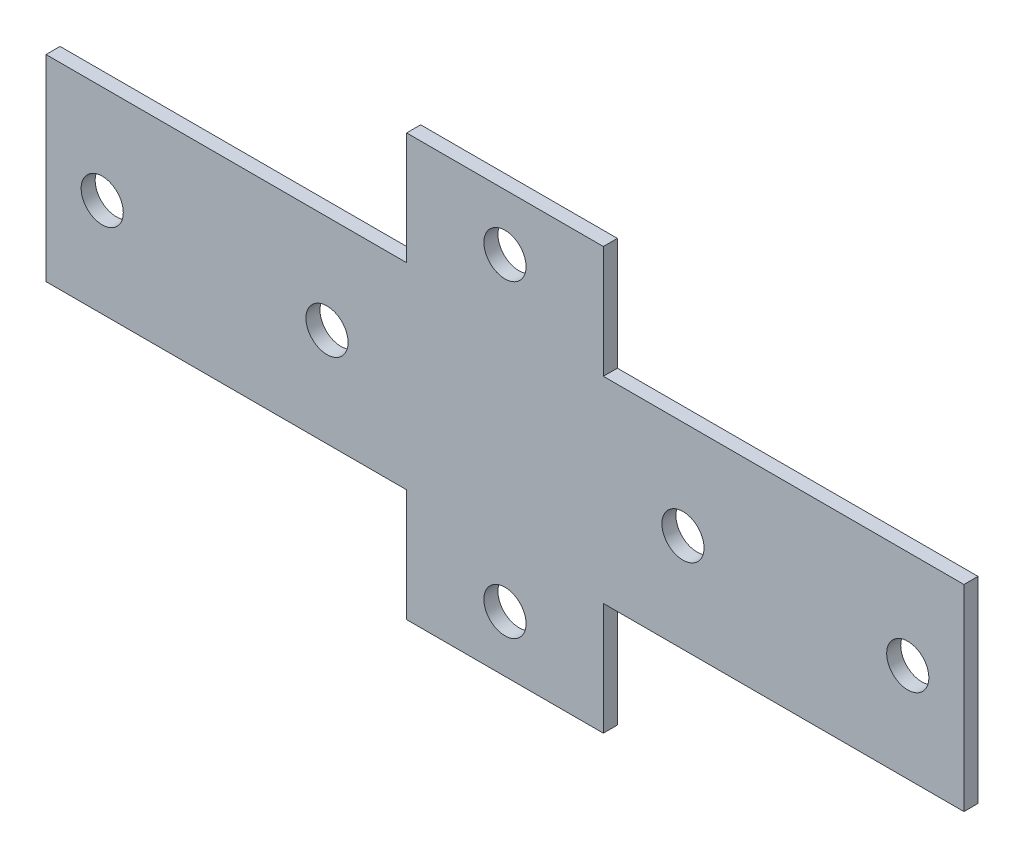
from build123d import *

# Parameters (mm, degrees)
SKETCH_1_R      = 4.5
EXTRUDE_1_DEPTH = 3


with BuildPart() as part:
    # Эскиз1 → Бобышка-Вытянуть1 (new body)
    with BuildSketch(Plane.XY):
        Polygon((21, -21), (98, -21), (98, 21), (21, 21), (21, 45), (-21, 45), (-21, 21), (-98, 21), (-98, -21), (-21, -21), (-21, -45), (21, -45), align=None)
        with Locations((0, 33)):
            Circle(SKETCH_1_R, mode=Mode.SUBTRACT)
        with Locations((0, -33)):
            Circle(SKETCH_1_R, mode=Mode.SUBTRACT)
        with Locations((-86, 0)):
            Circle(SKETCH_1_R, mode=Mode.SUBTRACT)
        with Locations((-38, 0)):
            Circle(SKETCH_1_R, mode=Mode.SUBTRACT)
        with Locations(Location((38, 0, 0), (0, 0, 180))):  # turned: the seam where the file's is
            Circle(SKETCH_1_R, mode=Mode.SUBTRACT)
        with Locations(Location((86, 0, 0), (0, 0, 180))):  # turned: the seam where the file's is
            Circle(SKETCH_1_R, mode=Mode.SUBTRACT)
    extrude(amount=EXTRUDE_1_DEPTH)


solid = part.part
